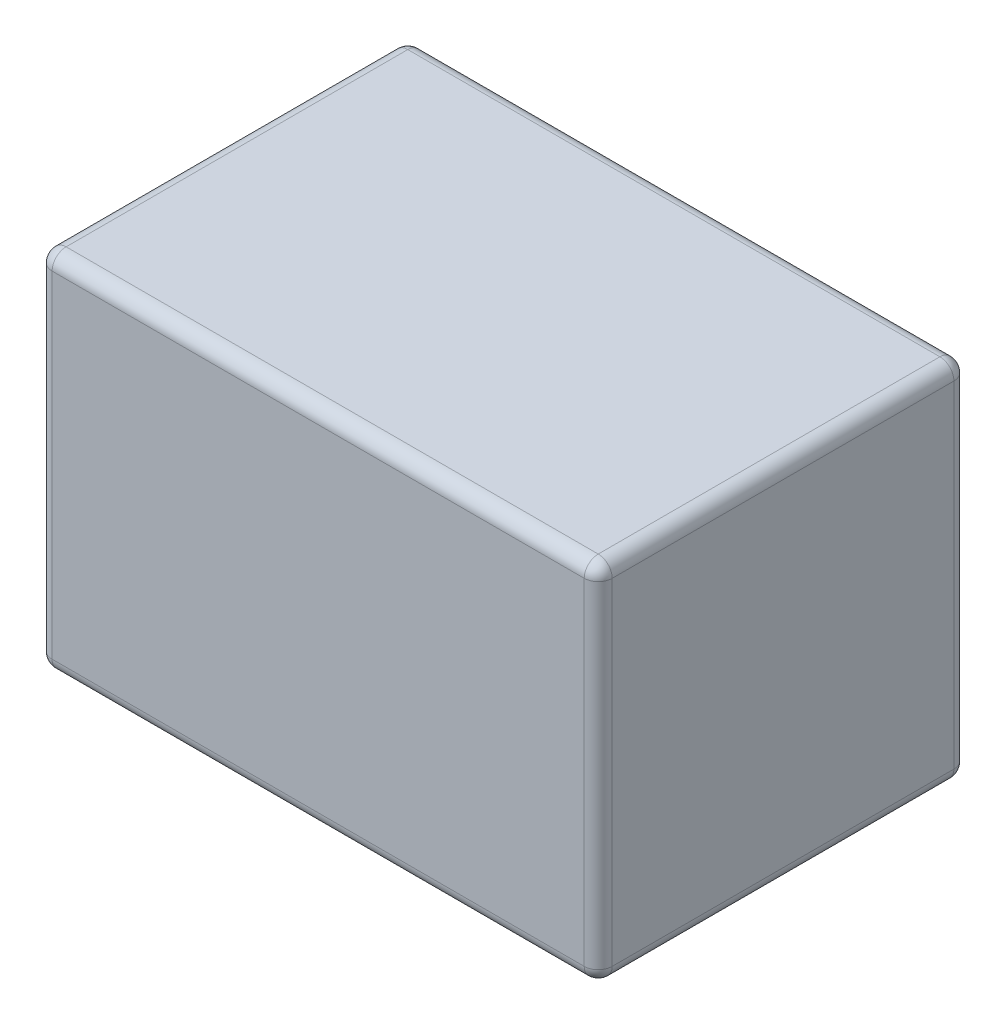
from build123d import *

# Parameters (mm, degrees)
SKETCH1_W           = 200
SKETCH1_H           = 130
BOSS_EXTRUDE1_DEPTH = 132
FILLET1_R           = 5
SKETCH2_W           = 190
SKETCH2_H           = 120
SKETCH2_R           = 0.25
BOSS_EXTRUDE2_DEPTH = 0.5


with BuildPart() as part:
    # Sketch1 → Boss-Extrude1 (new body)
    with BuildSketch(Plane.XY):
        with Locations((31.434425269, -19.677523207)):
            Rectangle(SKETCH1_W, SKETCH1_H)
    extrude(amount=BOSS_EXTRUDE1_DEPTH)

    # Fillet1
    fillet1_edges = [part.edges().sort_by_distance(p)[0] for p in [
        (131.434425269, -84.677523207, 66),
        (-68.565574731, -84.677523207, 66),
        (-68.565574731, 45.322476793, 66),
        (-68.565574731, -19.677523207, 132),
        (31.434425269, -84.677523207, 132),
        (131.434425269, -19.677523207, 132),
        (31.434425269, 45.322476793, 132),
        (131.434425269, -19.677523207, 0),
        (31.434425269, -84.677523207, 0),
        (-68.565574731, -19.677523207, 0),
        (31.434425269, 45.322476793, 0),
        (131.434425269, 45.322476793, 66),
    ]]
    fillet(fillet1_edges, radius=FILLET1_R)

    # Sketch2 → Boss-Extrude2 (add)
    with BuildSketch(Plane(origin=(0, 0, 0), x_dir=(-1, 0, 0), z_dir=(0, 0, -1))):
        with Locations((-31.434425269, -19.677523207)):
            Rectangle(SKETCH2_W, SKETCH2_H)
        with Locations((-31.434425269, -19.677523207)):
            Circle(SKETCH2_R, mode=Mode.SUBTRACT)
    extrude(amount=BOSS_EXTRUDE2_DEPTH)


solid = part.part
